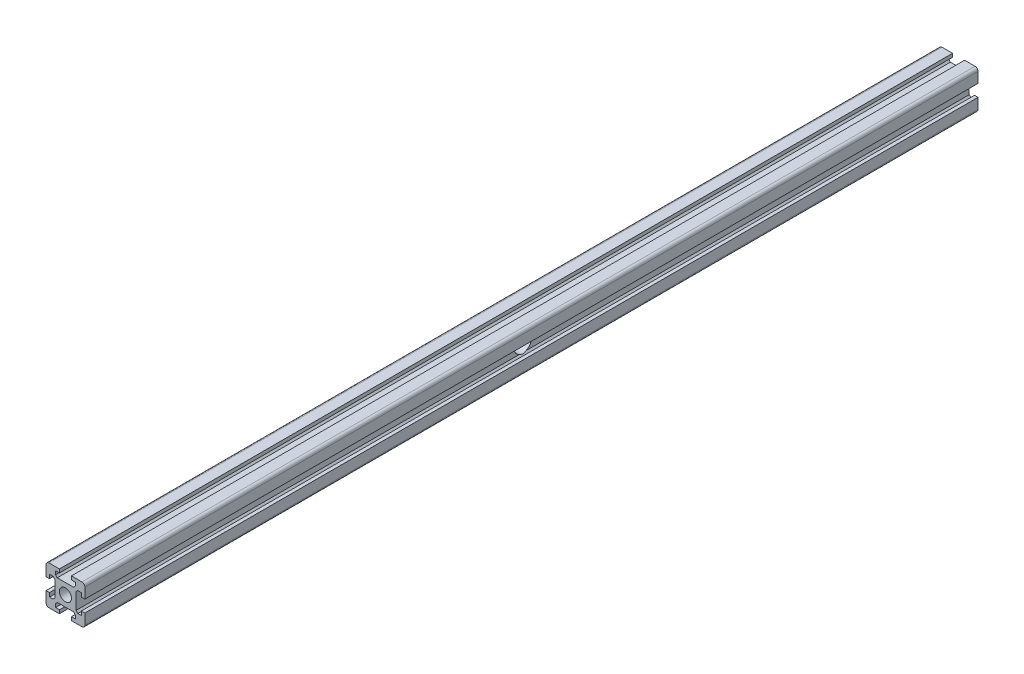
from build123d import *

# Parameters (mm, degrees)
SKETCH1_R               = 3.1
BOSS_EXTRUDE1_DEPTH     = 460
SKETCH5_R               = 4.5
CUT_EXTRUDE2_DEPTH      = 5.507107651
CUT_EXTRUDE2_DEPTH_BACK = 12


with BuildPart() as part:
    # Sketch1 → Boss-Extrude1 (new body)
    with BuildSketch(Plane.XY):
        with BuildLine():
            Line((-10, 3.1), (-8.2, 3.1))
            Line((-8.2, 3.1), (-8.2, 5.1))
            Line((-8.2, 5.1), (-6.4, 5.1))
            Line((-6.4, 5.1), (-5.492892349, 4.192892349))
            Line((-5.492892349, 4.192892349), (-5.492892349, -4.192892349))
            Line((-5.492892349, -4.192892349), (-6.4, -5.1))
            Line((-6.4, -5.1), (-8.2, -5.1))
            Line((-8.2, -5.1), (-8.2, -3.1))
            Line((-8.2, -3.1), (-10, -3.1))
            Line((-10, -3.1), (-10, -8.5))
            ThreePointArc((-10, -8.5), (-9.560660172, -9.560660172), (-8.5, -10))
            Line((-8.5, -10), (-3.1, -10))
            Line((-3.1, -10), (-3.1, -8.2))
            Line((-3.1, -8.2), (-5.1, -8.2))
            Line((-5.1, -8.2), (-5.1, -6.4))
            Line((-5.1, -6.4), (-4.192892349, -5.492892349))
            Line((-4.192892349, -5.492892349), (4.192892349, -5.492892349))
            Line((4.192892349, -5.492892349), (5.1, -6.4))
            Line((5.1, -6.4), (5.1, -8.2))
            Line((5.1, -8.2), (3.1, -8.2))
            Line((3.1, -8.2), (3.1, -10))
            Line((3.1, -10), (8.5, -10))
            ThreePointArc((8.5, -10), (9.560660172, -9.560660172), (10, -8.5))
            Line((10, -8.5), (10, -3.1))
            Line((10, -3.1), (8.2, -3.1))
            Line((8.2, -3.1), (8.2, -5.1))
            Line((8.2, -5.1), (6.4, -5.1))
            Line((6.4, -5.1), (5.492892349, -4.192892349))
            Line((5.492892349, -4.192892349), (5.492892349, 4.192892349))
            Line((5.492892349, 4.192892349), (6.4, 5.1))
            Line((6.4, 5.1), (8.2, 5.1))
            Line((8.2, 5.1), (8.2, 3.1))
            Line((8.2, 3.1), (10, 3.1))
            Line((10, 3.1), (10, 8.5))
            ThreePointArc((10, 8.5), (9.560660172, 9.560660172), (8.5, 10))
            Line((8.5, 10), (3.1, 10))
            Line((3.1, 10), (3.1, 8.2))
            Line((3.1, 8.2), (5.1, 8.2))
            Line((5.1, 8.2), (5.1, 6.4))
            Line((5.1, 6.4), (4.192892349, 5.492892349))
            Line((4.192892349, 5.492892349), (-4.192892349, 5.492892349))
            Line((-4.192892349, 5.492892349), (-5.1, 6.4))
            Line((-5.1, 6.4), (-5.1, 8.2))
            Line((-5.1, 8.2), (-3.1, 8.2))
            Line((-3.1, 8.2), (-3.1, 10))
            Line((-3.1, 10), (-8.5, 10))
            ThreePointArc((-8.5, 10), (-9.560660172, 9.560660172), (-10, 8.5))
            Line((-10, 8.5), (-10, 3.1))
        make_face()
        Circle(SKETCH1_R, mode=Mode.SUBTRACT)
    extrude(amount=BOSS_EXTRUDE1_DEPTH)

    # Sketch5 → Cut-Extrude2 (cut, two sides)
    with BuildSketch(Plane(origin=(-5.492892349, 0, 0), x_dir=(0, 0, -1), z_dir=(-1, 0, 0))) as cut_extrude2_sk:
        with Locations((-230, 0)):
            Circle(SKETCH5_R)
    extrude(amount=CUT_EXTRUDE2_DEPTH, mode=Mode.SUBTRACT)
    extrude(cut_extrude2_sk.sketch, amount=-CUT_EXTRUDE2_DEPTH_BACK, mode=Mode.SUBTRACT)


solid = part.part
